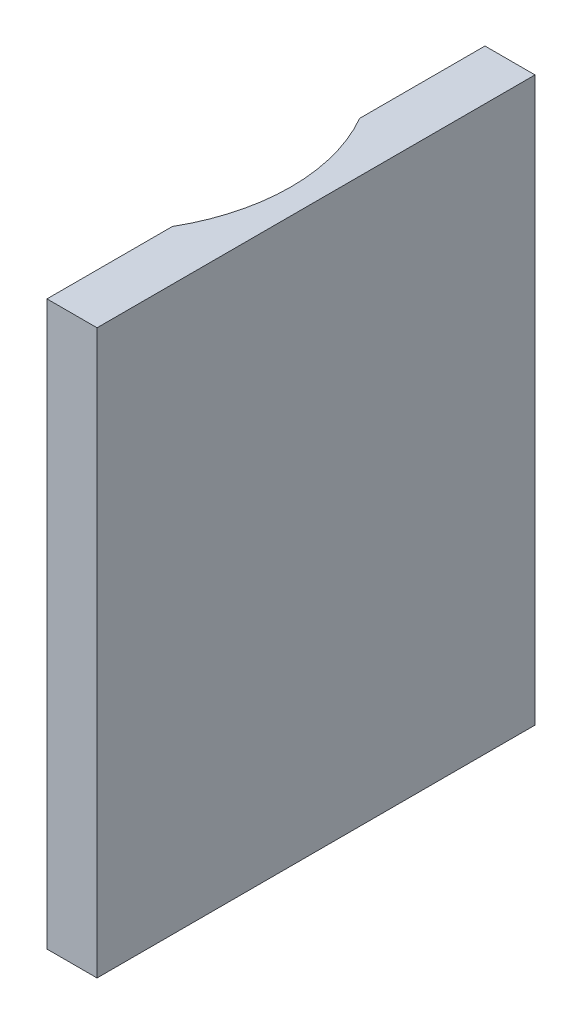
from build123d import *

# Parameters (mm, degrees)
SALIENTE_EXTRUIR1_DEPTH = 45


with BuildPart() as part:
    # Croquis1 → Saliente-Extruir1 (new body)
    with BuildSketch(Plane(origin=(0, 0, 0), x_dir=(1, 0, 0), z_dir=(0, 1, 0))):
        with BuildLine():
            Line((13, 17.5), (13, 7.483314774))
            ThreePointArc((13, 7.483314774), (15, 0), (13, -7.483314774))
            Line((13, -7.483314774), (13, -17.5))
            Line((13, -17.5), (17, -17.5))
            Line((17, -17.5), (17, 17.5))
            Line((17, 17.5), (13, 17.5))
        make_face()
    extrude(amount=SALIENTE_EXTRUIR1_DEPTH)


solid = part.part
